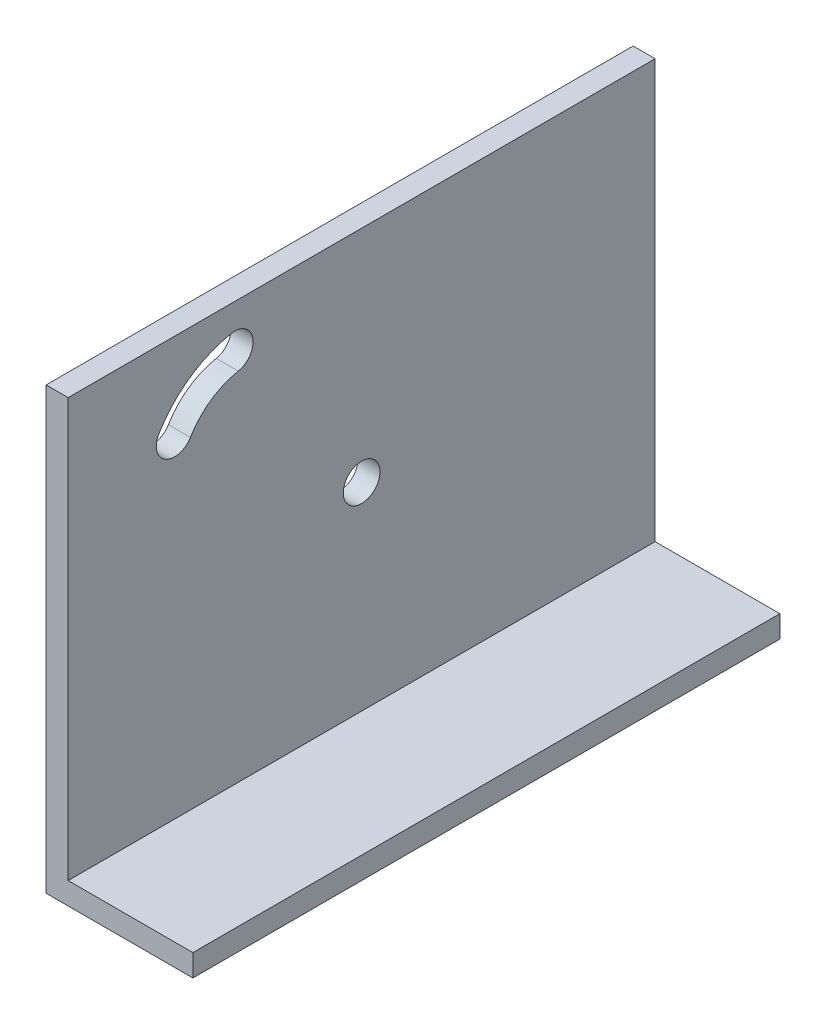
from build123d import *

# Parameters (mm, degrees)
BOSS_EXTRUDE1_DEPTH = 80
SKETCH2_R           = 2.5
CUT_EXTRUDE1_DEPTH  = 21
CUT_EXTRUDE2_DEPTH  = 10


with BuildPart() as part:
    # Sketch1 → Boss-Extrude1 (new body)
    with BuildSketch(Plane.XY):
        Polygon((0, 0), (20, 0), (20, 3), (3, 3), (3, 60), (0, 60), align=None)
    extrude(amount=BOSS_EXTRUDE1_DEPTH)

    # Sketch2 → Cut-Extrude1 (cut, through all)
    with BuildSketch(Plane.ZY):
        with Locations((40, 30)):
            Circle(SKETCH2_R)
    extrude(amount=-CUT_EXTRUDE1_DEPTH, mode=Mode.SUBTRACT)

    # Sketch3 → Cut-Extrude2 (cut)
    with BuildSketch(Plane.ZY):
        with BuildLine():
            ThreePointArc((57.758584744, 56.445517931), (63.433655861, 54.048079801), (67.628756298, 49.536397843))
            ThreePointArc((67.628756298, 49.536397843), (66.763094992, 46.108478576), (63.335175725, 46.974139881))
            ThreePointArc((63.335175725, 46.974139881), (60.566344139, 49.951920199), (56.820708869, 51.534266681))
            ThreePointArc((56.820708869, 51.534266681), (54.834021181, 54.458830243), (57.758584744, 56.445517931))
        make_face()
    extrude(amount=-CUT_EXTRUDE2_DEPTH, mode=Mode.SUBTRACT)


solid = part.part
